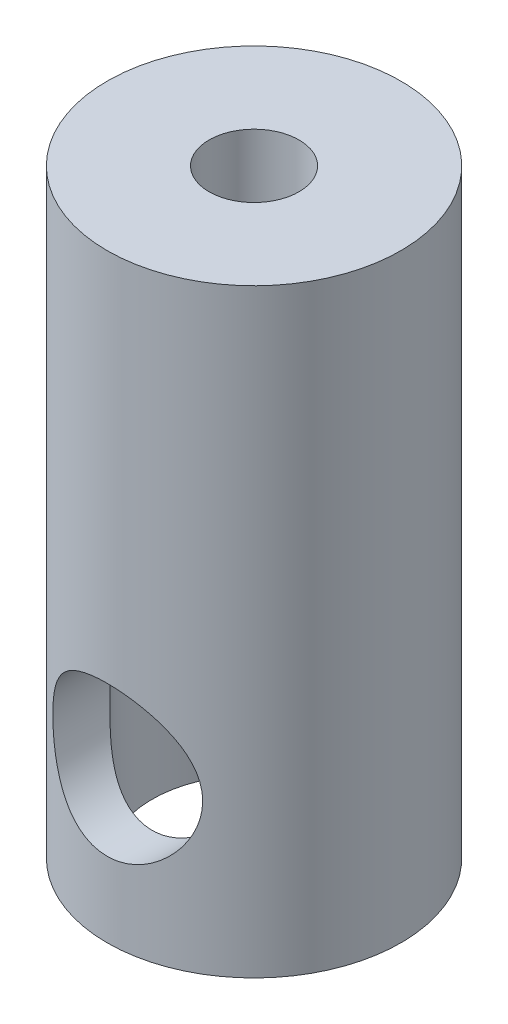
from build123d import *

# Parameters (mm, degrees)
SKETCH1_R               = 4.9
BOSS_EXTRUDE1_DEPTH     = 20
SKETCH2_R               = 1.5
CUT_EXTRUDE1_DEPTH      = 5
SKETCH3_R               = 3.4
CUT_EXTRUDE2_DEPTH      = 10
SKETCH4_R               = 2.5
CUT_EXTRUDE3_DEPTH      = 5.9
CUT_EXTRUDE3_DEPTH_BACK = 5.9


with BuildPart() as part:
    # Sketch1 → Boss-Extrude1 (new body)
    with BuildSketch(Plane(origin=(0, 0, 0), x_dir=(1, 0, 0), z_dir=(0, 1, 0))):
        Circle(SKETCH1_R)
    extrude(amount=BOSS_EXTRUDE1_DEPTH)

    # Sketch2 → Cut-Extrude1 (cut)
    with BuildSketch(Plane(origin=(0, 20, 0), x_dir=(1, 0, 0), z_dir=(0, 1, 0))):
        Circle(SKETCH2_R)
    extrude(amount=-CUT_EXTRUDE1_DEPTH, mode=Mode.SUBTRACT)

    # Sketch3 → Cut-Extrude2 (cut)
    with BuildSketch(Plane.XZ):
        Circle(SKETCH3_R)
    extrude(amount=-CUT_EXTRUDE2_DEPTH, mode=Mode.SUBTRACT)

    # Sketch4 → Cut-Extrude3 (cut, two sides)
    with BuildSketch(Plane.XY) as cut_extrude3_sk:
        with Locations((0, 5)):
            Circle(SKETCH4_R)
    extrude(amount=CUT_EXTRUDE3_DEPTH, mode=Mode.SUBTRACT)
    extrude(cut_extrude3_sk.sketch, amount=-CUT_EXTRUDE3_DEPTH_BACK, mode=Mode.SUBTRACT)


solid = part.part
